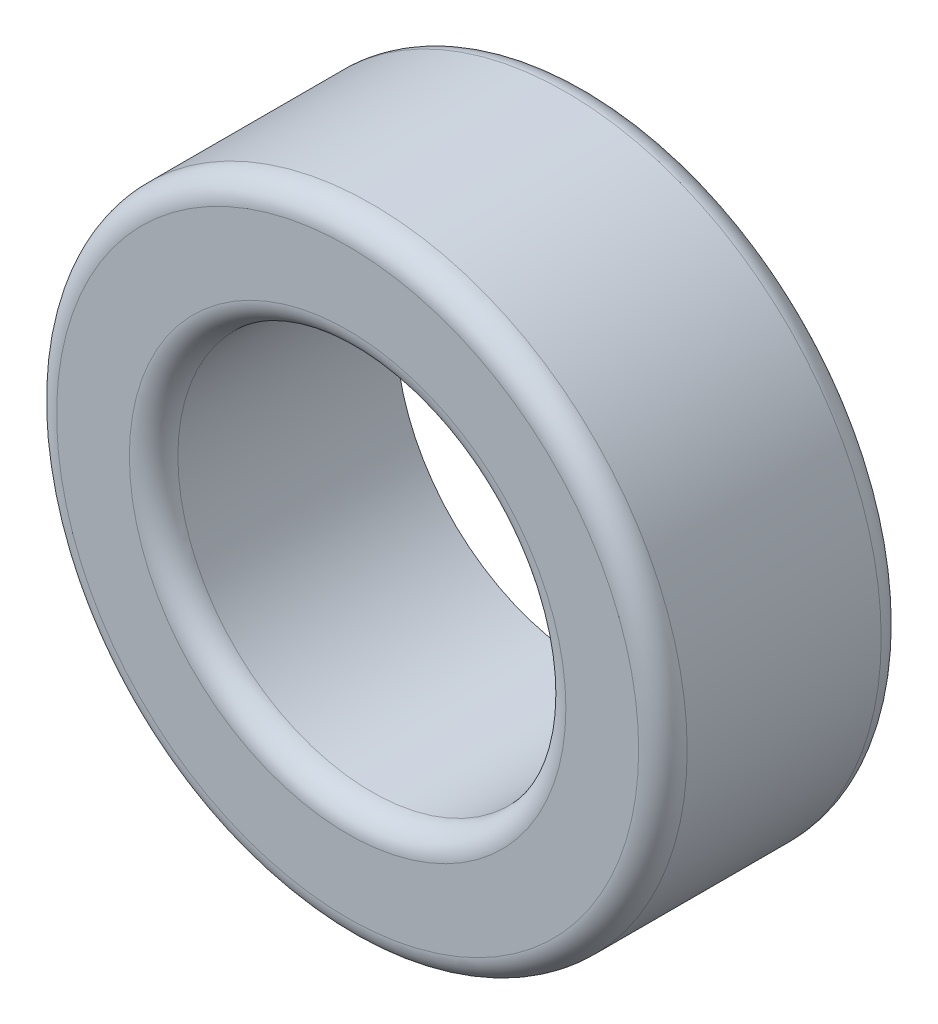
from build123d import *

# Parameters (mm, degrees)
SKETCH_1_R      = 6.5
SKETCH_1_R_2    = 4
EXTRUDE_1_DEPTH = 5
FILLET_1_R      = 0.5


with BuildPart() as part:
    # 草图1 → 凸台-拉伸1 (new body)
    with BuildSketch(Plane.XY):
        Circle(SKETCH_1_R)
        Circle(SKETCH_1_R_2, mode=Mode.SUBTRACT)
    extrude(amount=EXTRUDE_1_DEPTH)

    # 圆角1
    fillet_1_edges = [part.edges().sort_by_distance(p)[0] for p in [
        (-6.5, 0, 0),
        (-6.5, 0, 5),
        (-4, 0, 5),
    ]]
    fillet(fillet_1_edges, radius=FILLET_1_R)


solid = part.part
